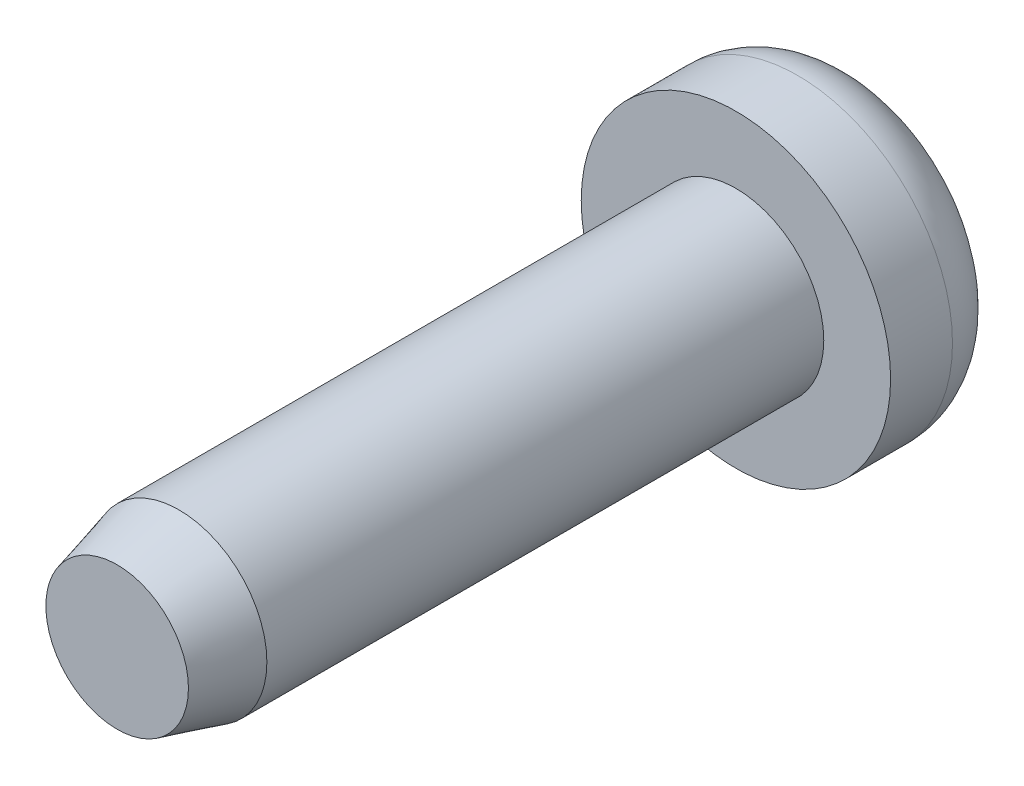
from build123d import *

# Parameters (mm, degrees)
SKETCH1_R           = 1.8034
BOSS_EXTRUDE1_DEPTH = 6.35
CHAMFER1_SIZE       = 1.27
CHAMFER1_SIZE2      = 0.340295474


with BuildPart() as part:
    # Sketch1 → Boss-Extrude1 (new body, symmetric)
    with BuildSketch(Plane.XY):
        Circle(SKETCH1_R)
    extrude(amount=BOSS_EXTRUDE1_DEPTH, both=True)

    # Chamfer1
    chamfer1_edges = [part.edges().sort_by_distance(p)[0] for p in [
        (-1.8034, 0, 6.35),
    ]]
    chamfer1_side = [part.faces().sort_by_distance(p)[0] for p in [
        (-1.8034, 0, 0),
    ]]
    chamfer(chamfer1_edges, length=CHAMFER1_SIZE, length2=CHAMFER1_SIZE2, reference=chamfer1_side[0])

    # Sketch2 → Revolve1 (revolve)
    with BuildSketch(Plane(origin=(0, 0, 0), x_dir=(1, 0, 0), z_dir=(0, 1, 0))):
        with BuildLine():
            Line((0, 6.35), (3.175, 6.35))
            Line((3.175, 6.35), (3.175, 7.62))
            ThreePointArc((3.175, 7.62), (2.803025612, 8.518025612), (1.905, 8.89))
            Line((1.905, 8.89), (0, 8.89))
            Line((0, 8.89), (0, 6.35))
        make_face()
    revolve(axis=Axis((0, 0, -6.35), (0, 0, -1)))


solid = part.part
